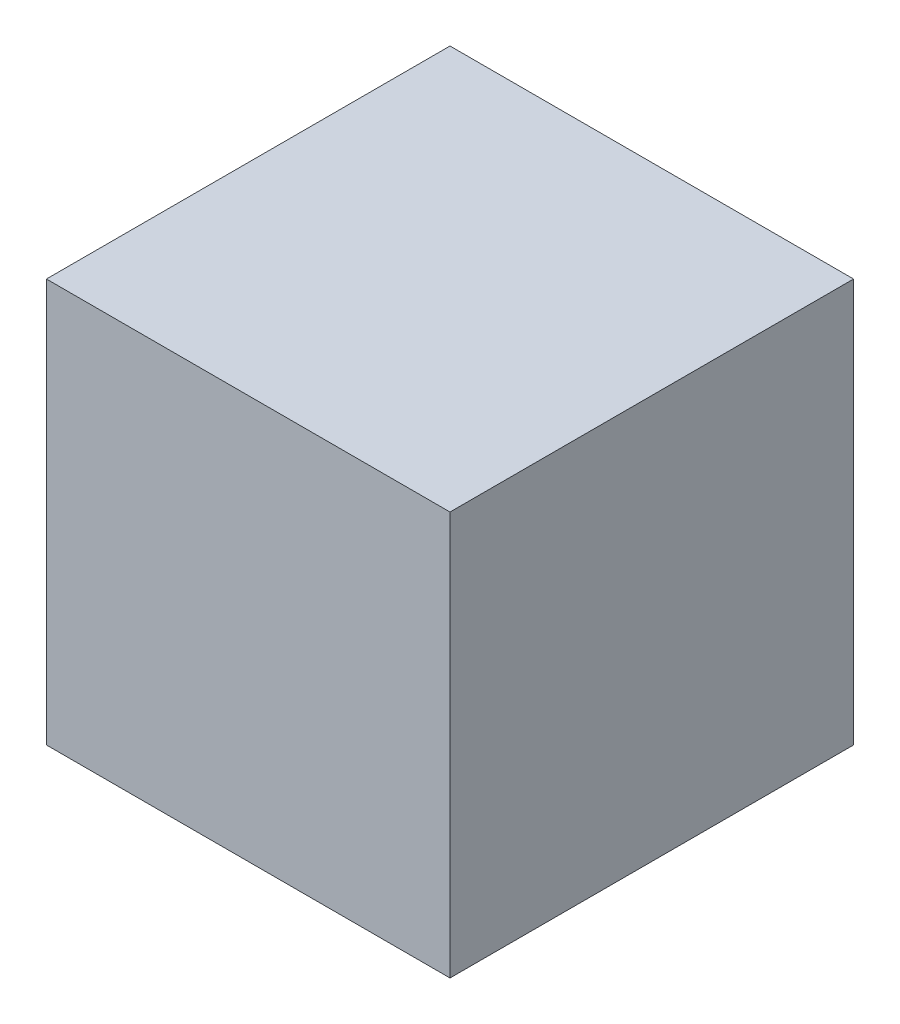
from build123d import *

# Parameters (mm, degrees)
SKETCH1_W           = 100
SKETCH1_H           = 100
BOSS_EXTRUDE1_DEPTH = 100


with BuildPart() as part:
    # Sketch1 → Boss-Extrude1 (new body)
    with BuildSketch(Plane(origin=(0, 0, 0), x_dir=(1, 0, 0), z_dir=(0, 1, 0))):
        with Locations((50, -50)):
            Rectangle(SKETCH1_W, SKETCH1_H)
    extrude(amount=BOSS_EXTRUDE1_DEPTH)


solid = part.part
